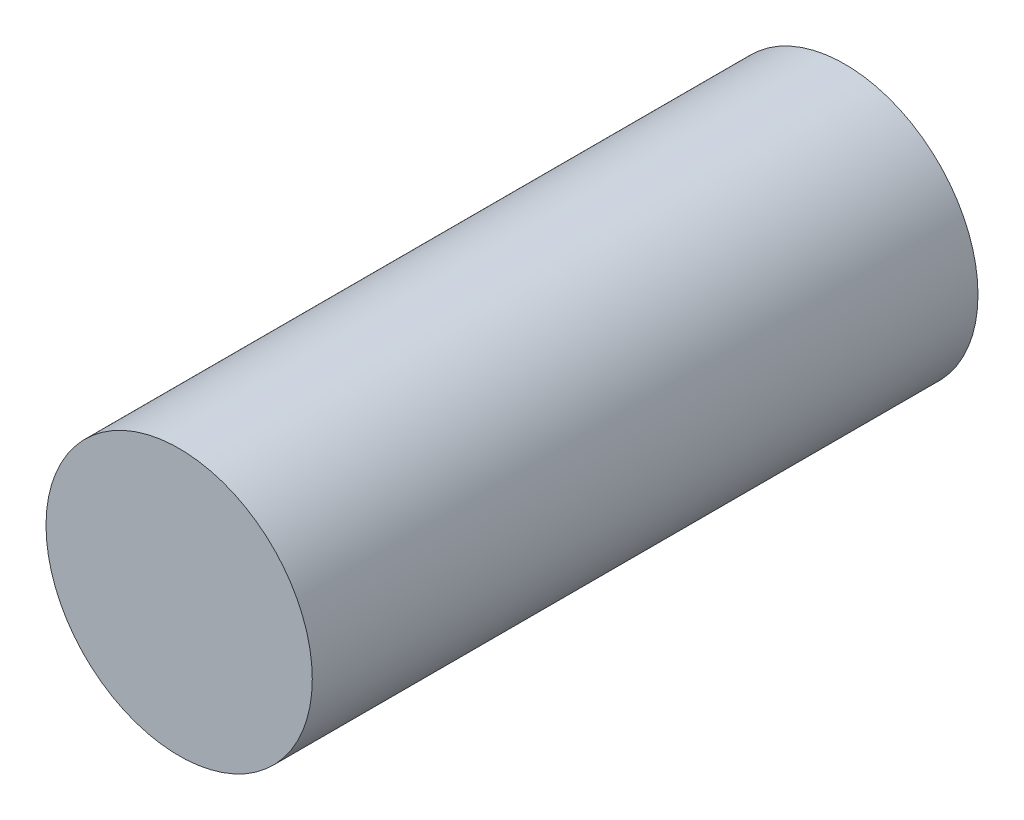
from build123d import *

# Parameters (mm, degrees)
SKETCH1_R           = 1
BOSS_EXTRUDE1_DEPTH = 5


with BuildPart() as part:
    # Sketch1 → Boss-Extrude1 (new body)
    with BuildSketch(Plane.XY):
        Circle(SKETCH1_R)
    extrude(amount=BOSS_EXTRUDE1_DEPTH)


solid = part.part
